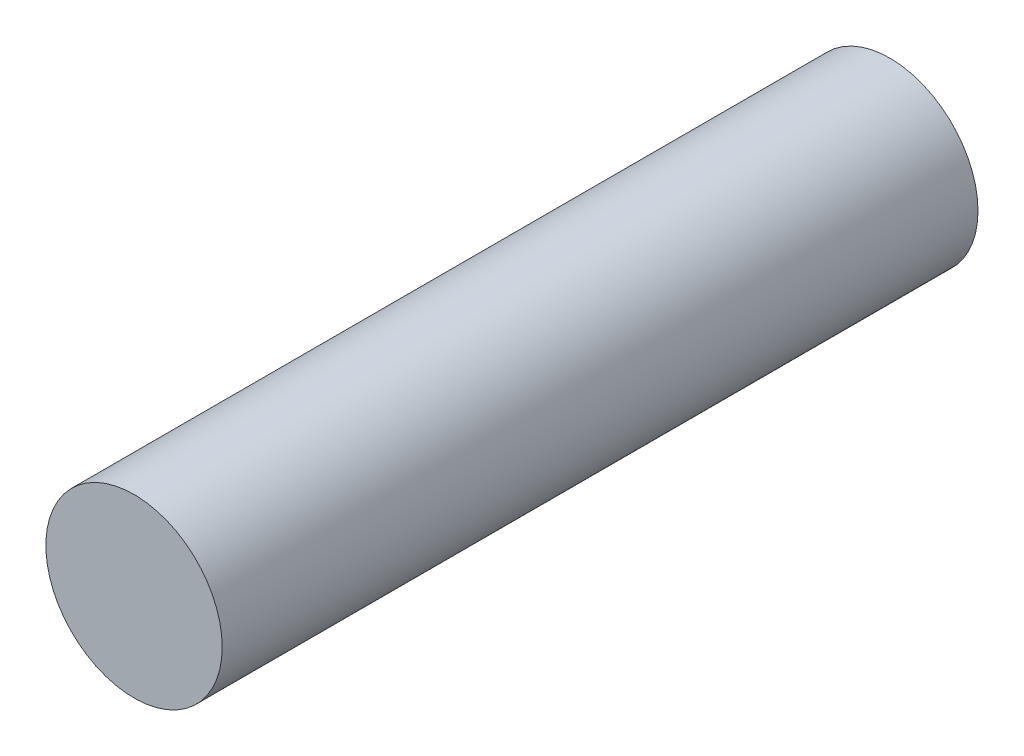
from build123d import *

# Parameters (mm, degrees)
SKETCH1_R           = 3.5
BOSS_EXTRUDE1_DEPTH = 30


with BuildPart() as part:
    # Sketch1 → Boss-Extrude1 (new body)
    with BuildSketch(Plane.XY):
        with Locations((0, 20.7)):
            Circle(SKETCH1_R)
    extrude(amount=BOSS_EXTRUDE1_DEPTH)


solid = part.part
